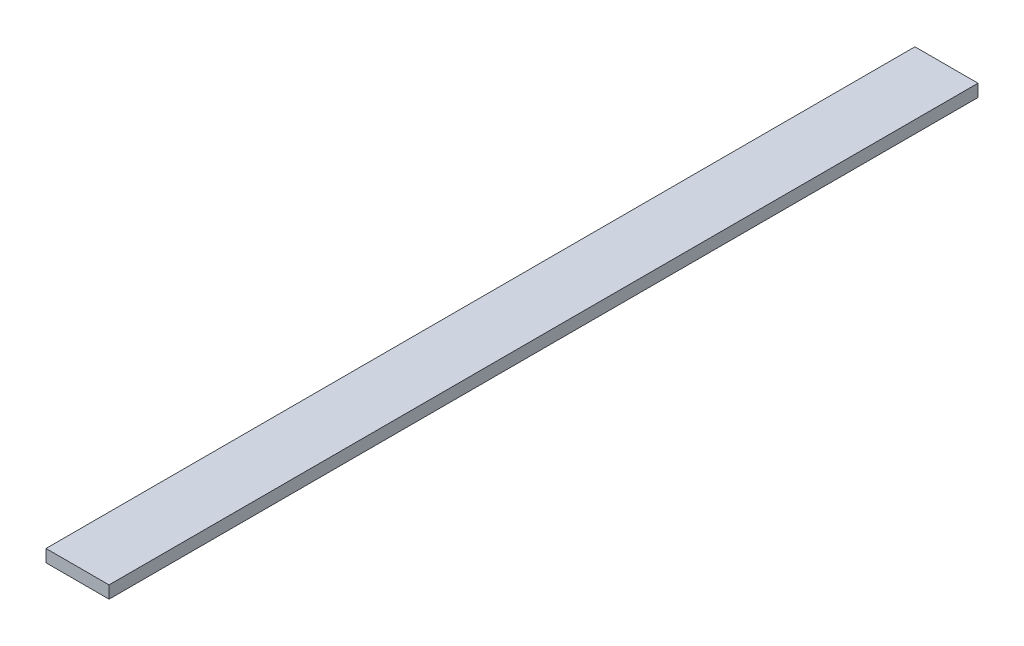
from build123d import *

# Parameters (mm, degrees)
CROQUIS1_W              = 50.8
CROQUIS1_H              = 10
SALIENTE_EXTRUIR1_DEPTH = 700


with BuildPart() as part:
    # Croquis1 → Saliente-Extruir1 (new body)
    with BuildSketch(Plane.XY):
        Rectangle(CROQUIS1_W, CROQUIS1_H)
    extrude(amount=SALIENTE_EXTRUIR1_DEPTH)


solid = part.part
